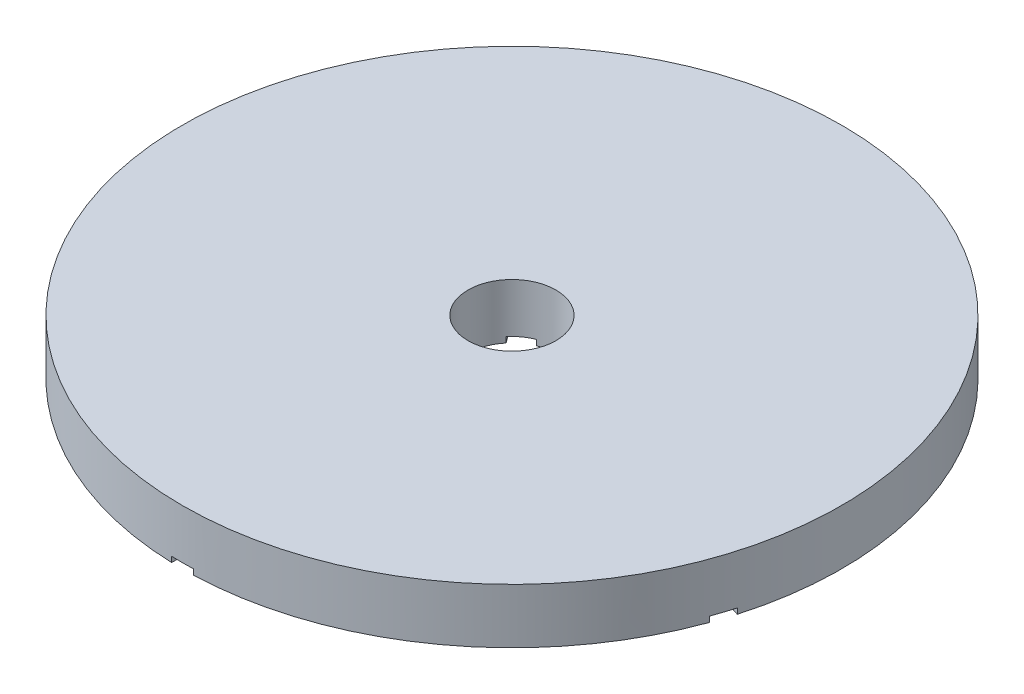
from build123d import *

# Parameters (mm, degrees)
SKETCH1_R           = 15
BOSS_EXTRUDE1_DEPTH = 2.5
CUT_EXTRUDE3_DEPTH  = 0.25
SKETCH3_R           = 2
CUT_EXTRUDE4_DEPTH  = 3.5


with BuildPart() as part:
    # Sketch1 → Boss-Extrude1 (new body)
    with BuildSketch(Plane(origin=(0, 0, 0), x_dir=(1, 0, 0), z_dir=(0, 1, 0))):
        Circle(SKETCH1_R)
    extrude(amount=BOSS_EXTRUDE1_DEPTH)

    # Sketch2 → Cut-Extrude3 (cut)
    with BuildSketch(Plane(origin=(0, 0, 0), x_dir=(1, 0, 0), z_dir=(0, 1, 0))):
        with BuildLine():
            Line((0, 0.850650808), (-8.412270287, 12.429147542))
            ThreePointArc((-8.412270287, 12.429147542), (-8.821675635, 12.141994852), (-9.221287282, 11.841362289))
            Line((-9.221287282, 11.841362289), (-0.809016994, 0.262865556))
            Line((-0.809016994, 0.262865556), (-14.420356242, -4.159726657))
            ThreePointArc((-14.420356242, -4.159726657), (-14.273771015, -4.637829342), (-14.111339247, -5.110783174))
            Line((-14.111339247, -5.110783174), (-0.5, -0.68819096))
            Line((-0.5, -0.68819096), (-0.5, -15))
            ThreePointArc((-0.5, -15), (0, -15.00833102), (0.5, -15))
            Line((0.5, -15), (0.5, -0.68819096))
            Line((0.5, -0.68819096), (14.111339247, -5.110783174))
            ThreePointArc((14.111339247, -5.110783174), (14.273771015, -4.637829342), (14.420356242, -4.159726657))
            Line((14.420356242, -4.159726657), (0.809016994, 0.262865556))
            Line((0.809016994, 0.262865556), (9.221287282, 11.841362289))
            ThreePointArc((9.221287282, 11.841362289), (8.821675635, 12.141994852), (8.412270287, 12.429147542))
            Line((8.412270287, 12.429147542), (0, 0.850650808))
        make_face()
    extrude(amount=CUT_EXTRUDE3_DEPTH, mode=Mode.SUBTRACT)

    # Sketch3 → Cut-Extrude4 (cut, through all)
    with BuildSketch(Plane(origin=(0, 0, 0), x_dir=(1, 0, 0), z_dir=(0, 1, 0))):
        Circle(SKETCH3_R)
    extrude(amount=CUT_EXTRUDE4_DEPTH, mode=Mode.SUBTRACT)


solid = part.part
